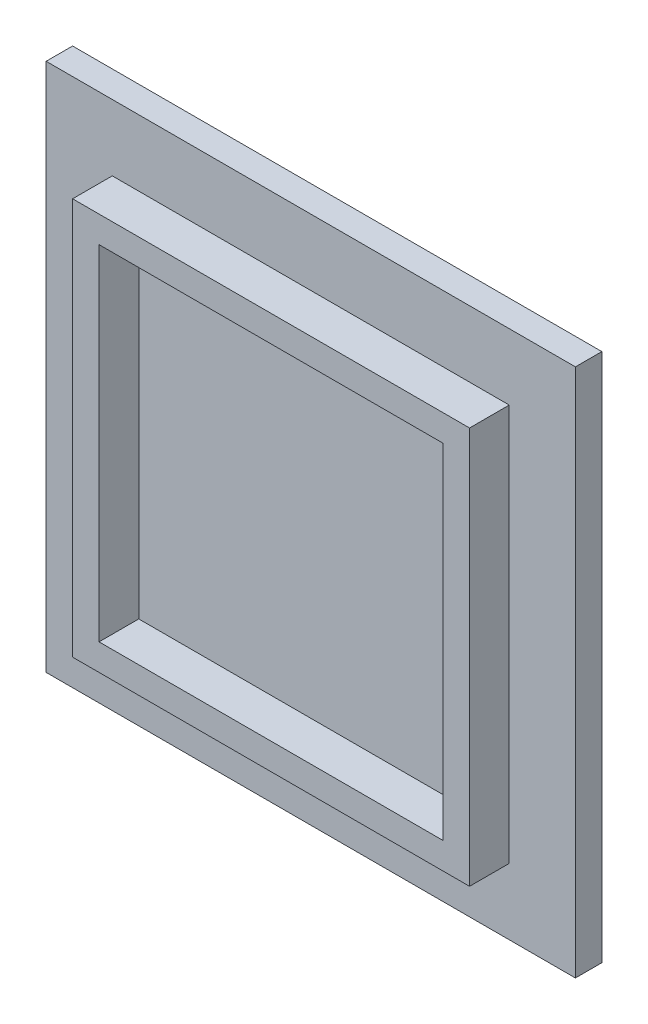
from build123d import *

# Parameters (mm, degrees)
SKETCH1_W           = 40
SKETCH1_H           = 40
BOSS_EXTRUDE1_DEPTH = 2
SKETCH2_W           = 30
SKETCH2_H           = 30
SKETCH2_W_2         = 26
SKETCH2_H_2         = 26
BOSS_EXTRUDE2_DEPTH = 3


with BuildPart() as part:
    # Sketch1 → Boss-Extrude1 (new body)
    with BuildSketch(Plane.XY):
        with Locations((-5.192307692, -4.855769231)):
            Rectangle(SKETCH1_W, SKETCH1_H)
    extrude(amount=BOSS_EXTRUDE1_DEPTH)

    # Sketch2 → Boss-Extrude2 (add)
    with BuildSketch(Plane.XY.offset(2)):
        with Locations((-5.192307692, -4.855769231)):
            Rectangle(SKETCH2_W, SKETCH2_H)
        with Locations((-5.192307692, -4.855769231)):
            Rectangle(SKETCH2_W_2, SKETCH2_H_2, mode=Mode.SUBTRACT)
    extrude(amount=BOSS_EXTRUDE2_DEPTH)


solid = part.part
